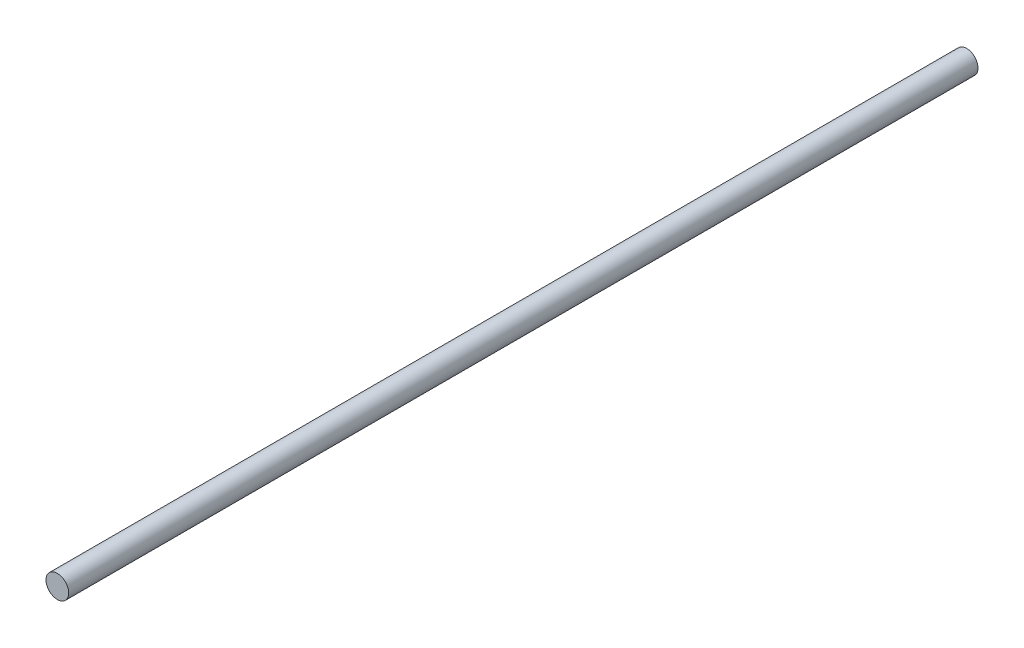
from build123d import *

# Parameters (mm, degrees)
SKETCH1_R           = 5
BOSS_EXTRUDE1_DEPTH = 400


with BuildPart() as part:
    # Sketch1 → Boss-Extrude1 (new body)
    with BuildSketch(Plane.XY):
        with Locations((-8.761117994, 6.924109382)):
            Circle(SKETCH1_R)
    extrude(amount=BOSS_EXTRUDE1_DEPTH)


solid = part.part
